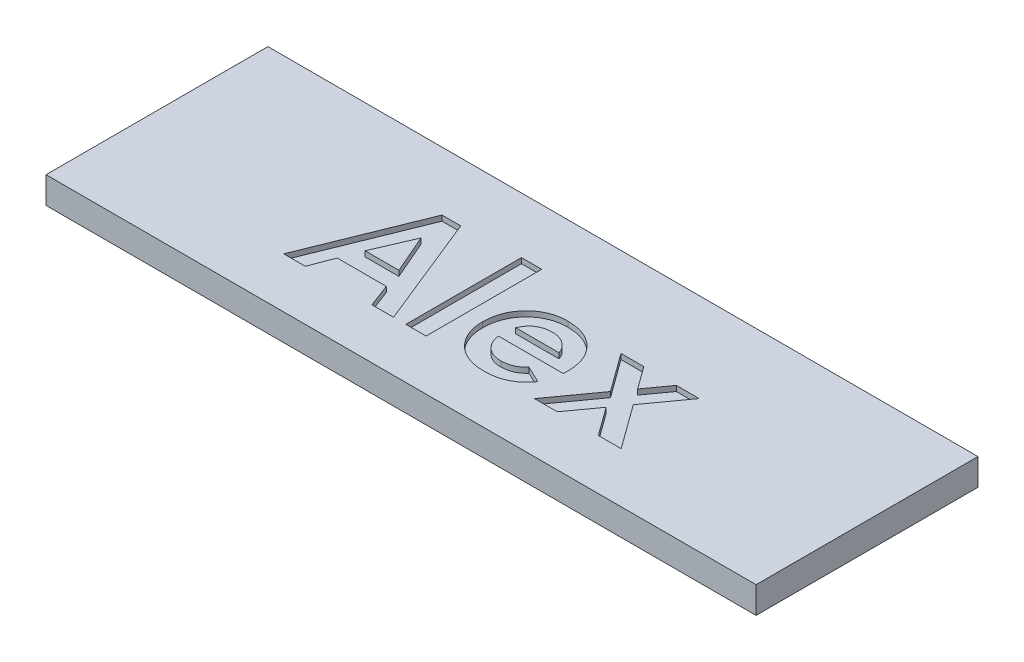
from build123d import *

# Parameters (mm, degrees)
SKETCH1_W           = 80
SKETCH1_H           = 25
BOSS_EXTRUDE1_DEPTH = 3
SKETCH2_R           = 2.25
CUT_EXTRUDE1_DEPTH  = 1.5
SKETCH3_W           = 2.27948718
SKETCH3_H           = 13.025641026
CUT_EXTRUDE2_DEPTH  = 0.6


with BuildPart() as part:
    # Sketch1 → Boss-Extrude1 (new body)
    with BuildSketch(Plane(origin=(0, 0, 0), x_dir=(1, 0, 0), z_dir=(0, 1, 0))):
        with Locations((21.96413767, -15.59699623)):
            Rectangle(SKETCH1_W, SKETCH1_H)
    extrude(amount=BOSS_EXTRUDE1_DEPTH)

    # Sketch2 → Cut-Extrude1 (cut)
    with BuildSketch(Plane.XZ):
        with Locations((-14.621648768, 24.682782668)):
            Circle(SKETCH2_R)
        with Locations((-14.621648768, 6.511209792)):
            Circle(SKETCH2_R)
        with Locations((54.549924108, 24.682782668)):
            Circle(SKETCH2_R)
        with Locations((54.549924108, 6.511209792)):
            Circle(SKETCH2_R)
    extrude(amount=-CUT_EXTRUDE1_DEPTH, mode=Mode.SUBTRACT)

    # Sketch3 → Cut-Extrude2 (cut)
    with BuildSketch(Plane(origin=(0, 3, 0), x_dir=(1, 0, 0), z_dir=(0, 1, 0))):
        Polygon((8.208348407, -9.727676223), (10.322471003, -9.727676223), (15.451317157, -22.427676223), (13.016641676, -22.427676223), (12.029542317, -19.822548017), (6.496188952, -19.822548017), (5.509089593, -22.427676223), (3.076958183, -22.427676223), align=None)
        Polygon((9.26413767, -13.134186639), (7.361172926, -17.543060838), (11.167102414, -17.543060838), align=None, mode=Mode.SUBTRACT)
        with Locations((17.975035106, -15.91485571)):
            Rectangle(SKETCH3_W, SKETCH3_H)
        with BuildLine():
            Line((30.504582382, -18.357163402), (23.185291516, -18.357163402))
            add(Edge.make_bspline(
                [(23.185291516, -18.357163402), (23.200214959, -18.442209409), (23.229540702, -18.609331524), (23.293222596, -18.852090897), (23.374490242, -19.080863232), (23.4718844, -19.295954343), (23.583763002, -19.498501331), (23.714260123, -19.687554172), (23.861720525, -19.862945882), (24.025291631, -20.02391419), (24.202247009, -20.168145283), (24.39172849, -20.294500838), (24.593931607, -20.398104663), (24.806538177, -20.485431937), (25.031136861, -20.554603985), (25.268058212, -20.602310631), (25.516674186, -20.630491122), (25.686038983, -20.634567107), (25.772611228, -20.636650582)],
                knots=[0, 0, 0, 0, 0.000258958, 0.000508874, 0.000751882, 0.000986434, 0.001216486, 0.001445127, 0.001674447, 0.001902918, 0.002132576, 0.002358368, 0.002584805, 0.002812992, 0.003047171, 0.003288657, 0.003537014, 0.003796708, 0.003796708, 0.003796708, 0.003796708], degree=3))
            add(Edge.make_bspline(
                [(25.772611228, -20.636650582), (25.877109804, -20.633891718), (26.082898275, -20.628458704), (26.384379918, -20.580275935), (26.675956582, -20.507497981), (26.954868926, -20.399271054), (27.22434771, -20.264547555), (27.479956487, -20.096698653), (27.726119644, -19.90062944), (27.876308179, -19.749499366), (27.952879657, -19.672447857)],
                knots=[0, 0, 0, 0, 0.000313293, 0.000616966, 0.000913762, 0.001213315, 0.001512543, 0.001815971, 0.002129057, 0.002454708, 0.002454708, 0.002454708, 0.002454708], degree=3))
            Line((27.952879657, -19.672447857), (29.860932542, -20.58068103))
            add(Edge.make_bspline(
                [(29.860932542, -20.58068103), (29.80085861, -20.663693984), (29.681824324, -20.828181098), (29.487504847, -21.05965695), (29.284720099, -21.27563331), (29.073318844, -21.474689669), (28.853032972, -21.656258795), (28.624475264, -21.822552529), (28.384305445, -21.969105949), (28.137325665, -22.103009223), (27.878430396, -22.217803878), (27.608336115, -22.315696709), (27.328186824, -22.404190994), (27.034444841, -22.471618792), (26.729556154, -22.524994087), (26.412791409, -22.562897617), (26.084192354, -22.586308811), (25.860845492, -22.58908418), (25.747170523, -22.590496735)],
                knots=[0, 0, 0, 0, 0.000307328, 0.000608958, 0.000905918, 0.001195685, 0.001479403, 0.001761841, 0.002042843, 0.002322841, 0.002604142, 0.002891486, 0.003184397, 0.003484921, 0.003794849, 0.004112613, 0.004441596, 0.004782587, 0.004782587, 0.004782587, 0.004782587], degree=3))
            add(Edge.make_bspline(
                [(25.747170523, -22.590496735), (25.572283449, -22.586931314), (25.229777196, -22.579948642), (24.728799885, -22.515139452), (24.253010391, -22.407678829), (23.801065249, -22.261602617), (23.374918069, -22.068736254), (22.974357949, -21.832844693), (22.59538272, -21.558450448), (22.249572192, -21.239794713), (21.934528598, -20.892956891), (21.657813893, -20.520476753), (21.426262969, -20.12495668), (21.236108693, -19.709014304), (21.088314183, -19.271584977), (20.981762915, -18.812477814), (20.916445711, -18.331912091), (20.909391129, -18.004593189), (20.905804337, -17.838173017)],
                knots=[0, 0, 0, 0, 0.000524474, 0.001027151, 0.001512262, 0.001986122, 0.002449541, 0.002912485, 0.003378599, 0.003850413, 0.004320515, 0.004782529, 0.005239796, 0.005692898, 0.006152277, 0.006622511, 0.007105006, 0.007604059, 0.007604059, 0.007604059, 0.007604059], degree=3))
            add(Edge.make_bspline(
                [(20.905804337, -17.838173017), (20.90942643, -17.667523896), (20.916552737, -17.331779412), (20.981200534, -16.840117207), (21.088608761, -16.371004964), (21.236835602, -15.923796664), (21.424105214, -15.497093634), (21.658602227, -15.094629011), (21.934391279, -14.715001634), (22.248299935, -14.359987439), (22.595575424, -14.039548341), (22.96458844, -13.753973068), (23.359485224, -13.516012794), (23.775799152, -13.323741041), (24.21086733, -13.167525095), (24.669718539, -13.063576429), (25.14886162, -12.993781123), (25.47639328, -12.987353411), (25.642863632, -12.984086479)],
                knots=[0, 0, 0, 0, 0.000511763, 0.001006871, 0.00148454, 0.001953567, 0.00241827, 0.002879933, 0.003348104, 0.003823893, 0.004299151, 0.00476372, 0.005221406, 0.00567895, 0.006137588, 0.006605345, 0.007088182, 0.007587235, 0.007587235, 0.007587235, 0.007587235], degree=3))
            add(Edge.make_bspline(
                [(25.642863632, -12.984086479), (25.818588533, -12.987707215), (26.163606266, -12.994816157), (26.66807273, -13.059099112), (27.147021409, -13.167215017), (27.602492893, -13.312028135), (28.028670625, -13.509766505), (28.434919021, -13.739853148), (28.811493942, -14.020178633), (29.162409274, -14.337274969), (29.479182079, -14.689082364), (29.756076609, -15.071252947), (29.991679775, -15.480056956), (30.182638479, -15.917152179), (30.33028123, -16.381226412), (30.436931131, -16.871676966), (30.501750121, -17.390369277), (30.508673433, -17.745547631), (30.512214593, -17.927215485)],
                knots=[0, 0, 0, 0, 0.000527016, 0.001034741, 0.001522334, 0.001998612, 0.002465399, 0.002929265, 0.003396883, 0.003870579, 0.004346163, 0.004814335, 0.005283879, 0.005758919, 0.00624246, 0.006742472, 0.00726282, 0.007807631, 0.007807631, 0.007807631, 0.007807631], degree=3))
            Line((30.512214593, -17.927215485), (30.504582382, -18.357163402))
        make_face()
        with BuildLine():
            add(Edge.make_bspline(
                [(28.232727414, -16.566137761), (28.189712096, -16.450056845), (28.10418644, -16.219257743), (27.910987542, -15.900811299), (27.654618786, -15.625023745), (27.356443531, -15.380866836), (27.015759632, -15.182693839), (26.643302634, -15.039210152), (26.243780323, -14.953175533), (25.968930502, -14.943085184), (25.828580779, -14.937932633)],
                knots=[0, 0, 0, 0, 0.000370859, 0.000737364, 0.00110838, 0.00149538, 0.001889834, 0.002285279, 0.002688448, 0.003109152, 0.003109152, 0.003109152, 0.003109152], degree=3))
            add(Edge.make_bspline(
                [(25.828580779, -14.937932633), (25.67529603, -14.942882285), (25.375656264, -14.952557826), (24.943446302, -15.055460748), (24.535753459, -15.209040286), (24.295400866, -15.36738405), (24.174934946, -15.446746735)],
                knots=[0, 0, 0, 0, 0.000458949, 0.00089715, 0.001326586, 0.001758097, 0.001758097, 0.001758097, 0.001758097], degree=3))
            add(Edge.make_bspline(
                [(24.174934946, -15.446746735), (24.099773209, -15.507191095), (23.939532227, -15.63605538), (23.731426804, -15.893127394), (23.52644123, -16.204383894), (23.409895629, -16.440805195), (23.348112029, -16.566137761)],
                knots=[0, 0, 0, 0, 0.000288637, 0.00061536, 0.000986515, 0.00140526, 0.00140526, 0.00140526, 0.00140526], degree=3))
            Line((23.348112029, -16.566137761), (28.232727414, -16.566137761))
        make_face(mode=Mode.SUBTRACT)
        Polygon((31.791882061, -13.146906992), (34.363937349, -13.146906992), (36.198212189, -15.675713082), (38.024854817, -13.146906992), (40.596910106, -13.146906992), (37.488055939, -17.45401837), (41.095547926, -22.427676223), (38.523492638, -22.427676223), (36.205844401, -19.232323659), (33.898372446, -22.427676223), (31.326317157, -22.427676223), (34.916000651, -17.45401837), align=None)
    extrude(amount=-CUT_EXTRUDE2_DEPTH, mode=Mode.SUBTRACT)


solid = part.part
